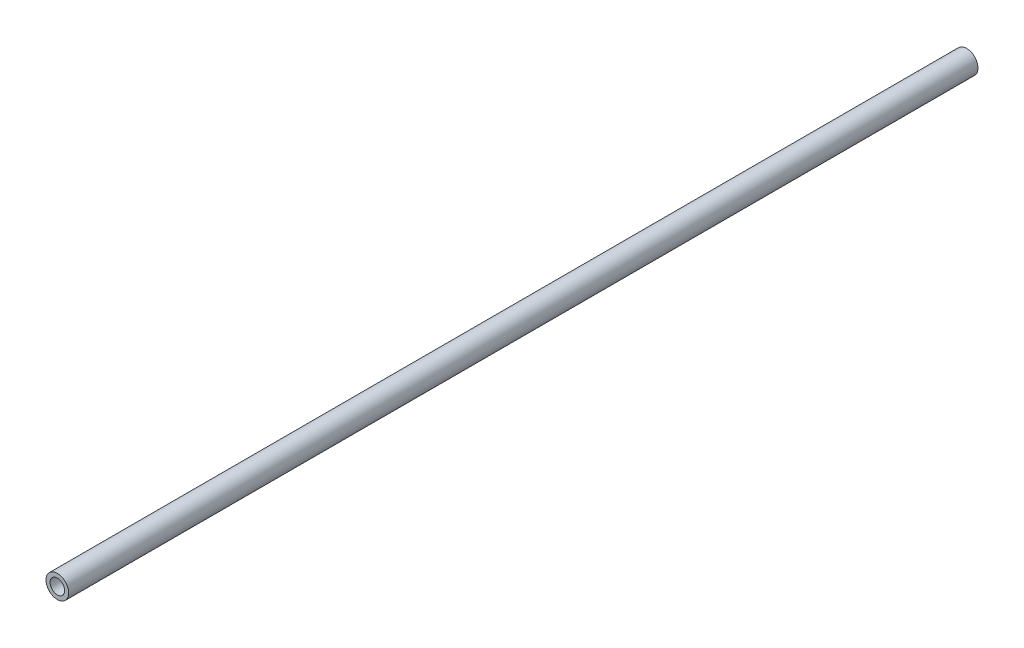
from build123d import *

# Parameters (mm, degrees)
SKETCH1_R           = 2.5
SKETCH1_R_2         = 1.6
BOSS_EXTRUDE2_DEPTH = 200


with BuildPart() as part:
    # Sketch1 → Boss-Extrude2 (new body)
    with BuildSketch(Plane.XY):
        Circle(SKETCH1_R)
        Circle(SKETCH1_R_2, mode=Mode.SUBTRACT)
    extrude(amount=BOSS_EXTRUDE2_DEPTH)


solid = part.part
